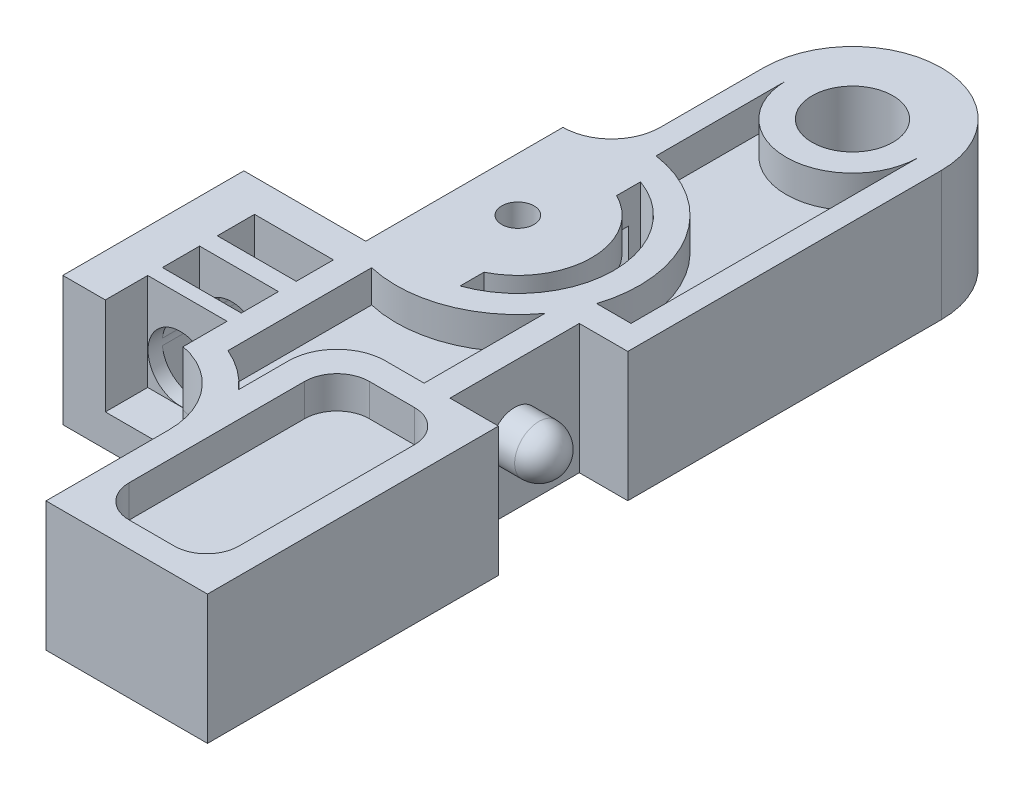
from build123d import *

# Parameters (mm, degrees)
SKETCH1_W           = 21.55
SKETCH1_H           = 50.9
BOSS_EXTRUDE1_DEPTH = 8
SKETCH2_W           = 3
SKETCH2_H           = 8
SKETCH2_W_2         = 11.56
SKETCH2_H_2         = 12.6
CUT_EXTRUDE1_DEPTH  = 10
SKETCH4_R           = 1
CUT_EXTRUDE2_DEPTH  = 10
CUT_EXTRUDE3_START  = -2
SKETCH5_R           = 5.25
CUT_EXTRUDE3_DEPTH  = 4
CUT_EXTRUDE4_DEPTH  = 8
SKETCH7_R           = 2.5
CUT_EXTRUDE5_DEPTH  = 8
SKETCH8_R           = 1.5
BOSS_EXTRUDE2_DEPTH = 3
FILLET1_R           = 1.5
CUT_EXTRUDE6_REACH  = 40.3
SKETCH9_R           = 2
FILLET2_R           = 5
SKETCH10_W          = 4.879401489
SKETCH10_H          = 2.3
CUT_EXTRUDE7_DEPTH  = 8
SKETCH11_W          = 4.90836959
SKETCH11_H          = 2.717270837
CUT_EXTRUDE8_DEPTH  = 6
CUT_EXTRUDE9_DEPTH  = 2
CUT_EXTRUDE11_DEPTH = 2
CUT_EXTRUDE12_DEPTH = 2
FILLET3_R           = 3
FILLET4_R           = 2
CUT_EXTRUDE13_DEPTH = 2
SKETCH16_W          = 2
SKETCH16_H          = 3
CUT_EXTRUDE14_DEPTH = 7
BOSS_EXTRUDE3_DEPTH = 2


with BuildPart() as part:
    # Sketch1 → Boss-Extrude1 (new body)
    with BuildSketch(Plane(origin=(0, 0, 0), x_dir=(1, 0, 0), z_dir=(0, 1, 0))):
        with Locations((-10.785, 25.45)):
            Rectangle(SKETCH1_W, SKETCH1_H)
    extrude(amount=BOSS_EXTRUDE1_DEPTH)

    # Sketch2 → Cut-Extrude1 (cut)
    with BuildSketch(Plane(origin=(0, 8, 0), x_dir=(1, 0, 0), z_dir=(0, 1, 0))):
        with BuildLine():
            ThreePointArc((-14.020598511, 36), (-11.891783888, 36.881783888), (-11.01, 39.010598511))
            Line((-11.01, 39.010598511), (-11.01, 45.4))
            ThreePointArc((-11.01, 45.4), (-9.399087308, 49.289087285), (-5.510000032, 50.9))
            Line((-5.510000032, 50.9), (-21.56, 50.9))
            Line((-21.56, 50.9), (-21.56, 23.8))
            Line((-21.56, 23.8), (-14.020598511, 23.8))
            Line((-14.020598511, 23.8), (-14.020598511, 36))
        make_face()
        with BuildLine():
            Line((-0.01, 50.9), (-5.510000032, 50.9))
            ThreePointArc((-5.510000032, 50.9), (-1.620912715, 49.289087308), (-0.01, 45.4))
            Line((-0.01, 45.4), (-0.01, 50.9))
        make_face()
        with Locations((-1.51, 22)):
            Rectangle(SKETCH2_W, SKETCH2_H)
        with Locations((-15.78, 6.3)):
            Rectangle(SKETCH2_W_2, SKETCH2_H_2)
    extrude(amount=-CUT_EXTRUDE1_DEPTH, mode=Mode.SUBTRACT)

    # Sketch4 → Cut-Extrude2 (cut)
    with BuildSketch(Plane(origin=(0, 8, 0), x_dir=(1, 0, 0), z_dir=(0, 1, 0))):
        with Locations((-10.71, 29.9)):
            Circle(SKETCH4_R)
    extrude(amount=-CUT_EXTRUDE2_DEPTH, mode=Mode.SUBTRACT)

    # Sketch5 → Cut-Extrude3 (cut)
    with BuildSketch(Plane(origin=(0, 8, 0), x_dir=(1, 0, 0), z_dir=(0, 1, 0)).offset(CUT_EXTRUDE3_START)):
        with Locations((-10.71, 29.9)):
            Circle(SKETCH5_R)
    extrude(amount=-CUT_EXTRUDE3_DEPTH, mode=Mode.SUBTRACT)

    # Sketch6 → Cut-Extrude4 (cut)
    with BuildSketch(Plane(origin=(0, 8, 0), x_dir=(1, 0, 0), z_dir=(0, 1, 0))):
        with BuildLine():
            Line((-8.703613469, 35.482647313), (-8.703613469, 33.999886934))
            ThreePointArc((-8.703613469, 33.999886934), (-6.145500051, 29.9), (-8.703613469, 25.800113066))
            Line((-8.703613469, 25.800113066), (-8.703613469, 24.317352687))
            ThreePointArc((-8.703613469, 24.317352687), (-4.777754394, 29.9), (-8.703613469, 35.482647313))
        make_face()
    extrude(amount=-CUT_EXTRUDE4_DEPTH, mode=Mode.SUBTRACT)

    # Sketch7 → Cut-Extrude5 (cut)
    with BuildSketch(Plane(origin=(0, 8, 0), x_dir=(1, 0, 0), z_dir=(0, 1, 0))):
        with Locations((-5.51, 45.4)):
            Circle(SKETCH7_R)
    extrude(amount=-CUT_EXTRUDE5_DEPTH, mode=Mode.SUBTRACT)

    # Sketch8 → Boss-Extrude2 (add)
    with BuildSketch(Plane(origin=(-3.01, 0, 0), x_dir=(0, 0, -1), z_dir=(1, 0, 0))):
        with Locations((22, 4)):
            Circle(SKETCH8_R)
    extrude(amount=BOSS_EXTRUDE2_DEPTH)

    # Fillet1
    fillet1_edges = [part.edges().sort_by_distance(p)[0] for p in [
        (-0.01, 4, -20.5),
    ]]
    fillet(fillet1_edges, radius=FILLET1_R)

    # Sketch9 → Cut-Extrude6 (cut, up to next)
    with BuildSketch(Plane.XY.offset(-12.6), mode=Mode.PRIVATE) as cut_extrude6_sk1:
        with Locations((-16.91, 4.013647605)):
            Circle(SKETCH9_R)
    cut_extrude6_tool1 = extrude(cut_extrude6_sk1.sketch, amount=-CUT_EXTRUDE6_REACH, mode=Mode.PRIVATE) & part.part
    add(cut_extrude6_tool1.solids().sort_by_distance((-16.91, 4.013648, -12.6))[0], mode=Mode.SUBTRACT)

    # Fillet2
    fillet2_edges = [part.edges().sort_by_distance(p)[0] for p in [
        (-10, 4, -12.6),
    ]]
    fillet(fillet2_edges, radius=FILLET2_R)

    # Sketch10 → Cut-Extrude7 (cut)
    with BuildSketch(Plane(origin=(0, 8, 0), x_dir=(1, 0, 0), z_dir=(0, 1, 0))):
        with Locations((-16.460299256, 20.65)):
            Rectangle(SKETCH10_W, SKETCH10_H)
        with Locations((-16.460299256, 17.25)):
            Rectangle(SKETCH10_W, SKETCH10_H)
    extrude(amount=-CUT_EXTRUDE7_DEPTH, mode=Mode.SUBTRACT)

    # Sketch11 → Cut-Extrude8 (cut)
    with BuildSketch(Plane(origin=(0, 8, 0), x_dir=(1, 0, 0), z_dir=(0, 1, 0))):
        with Locations((-16.474783306, 13.861774486)):
            Rectangle(SKETCH11_W, SKETCH11_H)
    extrude(amount=-CUT_EXTRUDE8_DEPTH, mode=Mode.SUBTRACT)

    # Sketch12 → Cut-Extrude9 (cut)
    with BuildSketch(Plane(origin=(0, 8, 0), x_dir=(1, 0, 0), z_dir=(0, 1, 0))):
        with BuildLine():
            Line((-9.61, 45.4), (-9.61, 37.351491386))
            ThreePointArc((-9.61, 37.351491386), (-4.316139602, 33.881616893), (-3.537502257, 27.6))
            Line((-3.537502257, 27.6), (-1.41, 27.6))
            Line((-1.41, 27.6), (-1.41, 45.4))
            ThreePointArc((-1.41, 45.4), (-5.51, 41.3), (-9.61, 45.4))
        make_face()
    extrude(amount=-CUT_EXTRUDE9_DEPTH, mode=Mode.SUBTRACT)

    # Sketch13 → Cut-Extrude11 (cut)
    with BuildSketch(Plane.XZ):
        with BuildLine():
            Line((-1.41, -27.6), (-3.537502257, -27.6))
            ThreePointArc((-3.537502257, -27.6), (-4.316139602, -33.881616893), (-9.61, -37.351491386))
            Line((-9.61, -37.351491386), (-9.61, -45.4))
            ThreePointArc((-9.61, -45.4), (-5.51, -41.3), (-1.41, -45.4))
            Line((-1.41, -45.4), (-1.41, -27.6))
        make_face()
    extrude(amount=-CUT_EXTRUDE11_DEPTH, mode=Mode.SUBTRACT)

    # Sketch14 → Cut-Extrude12 (cut)
    with BuildSketch(Plane(origin=(0, 8, 0), x_dir=(1, 0, 0), z_dir=(0, 1, 0))):
        with BuildLine():
            Line((-12.420598511, 22.564567047), (-12.420598511, 13.675087486))
            ThreePointArc((-12.420598511, 13.675087486), (-11.108680842, 12.930819375), (-10, 11.908131846))
            Line((-10, 11.908131846), (-10, 18))
            Line((-10, 18), (-4.61, 18))
            Line((-4.61, 18), (-4.61, 25.481321027))
            ThreePointArc((-4.61, 25.481321027), (-8.074933625, 22.843715633), (-12.420598511, 22.564567047))
        make_face()
        with BuildLine():
            Line((-6.4, 16.4), (-3.61, 16.4))
            ThreePointArc((-3.61, 16.4), (-2.195786438, 15.814213562), (-1.61, 14.4))
            Line((-1.61, 14.4), (-1.61, 1.546839651))
            Line((-1.61, 1.546839651), (-8.4, 1.546839651))
            Line((-8.4, 1.546839651), (-8.4, 14.4))
            ThreePointArc((-8.4, 14.4), (-7.814213562, 15.814213562), (-6.4, 16.4))
        make_face()
    extrude(amount=-CUT_EXTRUDE12_DEPTH, mode=Mode.SUBTRACT)

    # Fillet3
    fillet3_edges = [part.edges().sort_by_distance(p)[0] for p in [
        (-10, 7, -18),
    ]]
    fillet(fillet3_edges, radius=FILLET3_R)

    # Fillet4
    fillet4_edges = [part.edges().sort_by_distance(p)[0] for p in [
        (-1.61, 7, -1.546839651),
        (-8.4, 7, -1.546839651),
    ]]
    fillet(fillet4_edges, radius=FILLET4_R)

    # Sketch15 → Cut-Extrude13 (cut)
    with BuildSketch(Plane(origin=(0, 0, 0), x_dir=(-1, 0, 0), z_dir=(0, -1, 0))):
        with BuildLine():
            Line((6.4, 1.546839651), (3.61, 1.546839651))
            ThreePointArc((3.61, 1.546839651), (2.195786438, 2.132626089), (1.61, 3.546839651))
            Line((1.61, 3.546839651), (1.61, 14.4))
            ThreePointArc((1.61, 14.4), (2.195786438, 15.814213562), (3.61, 16.4))
            Line((3.61, 16.4), (6.4, 16.4))
            ThreePointArc((6.4, 16.4), (7.814213562, 15.814213562), (8.4, 14.4))
            Line((8.4, 14.4), (8.4, 3.546839651))
            ThreePointArc((8.4, 3.546839651), (7.814213562, 2.132626089), (6.4, 1.546839651))
        make_face()
        with BuildLine():
            Line((4.61, 18), (4.61, 25.481321027))
            ThreePointArc((4.61, 25.481321027), (8.074933625, 22.843715633), (12.420598511, 22.564567047))
            Line((12.420598511, 22.564567047), (12.420598511, 13.675087486))
            ThreePointArc((12.420598511, 13.675087486), (11.108680842, 12.930819375), (10, 11.908131846))
            Line((10, 11.908131846), (10, 15))
            ThreePointArc((10, 15), (9.121320344, 17.121320344), (7, 18))
            Line((7, 18), (4.61, 18))
        make_face()
    extrude(amount=-CUT_EXTRUDE13_DEPTH, mode=Mode.SUBTRACT)

    # Sketch16 → Cut-Extrude14 (cut)
    with BuildSketch(Plane.ZY.offset(21.56)):
        with Locations((-22.8, 4)):
            Rectangle(SKETCH16_W, SKETCH16_H)
    extrude(amount=-CUT_EXTRUDE14_DEPTH, mode=Mode.SUBTRACT)

    # Sketch17 → Boss-Extrude3 (add)
    with BuildSketch(Plane(origin=(0, 0, -23.8), x_dir=(-1, 0, 0), z_dir=(0, 0, -1))):
        with BuildLine():
            Line((15.602762099, 2.5), (18.217237901, 2.5))
            ThreePointArc((18.217237901, 2.5), (16.91, 2.013647605), (15.602762099, 2.5))
        make_face()
        with BuildLine():
            Line((15.571808475, 5.5), (18.248191525, 5.5))
            ThreePointArc((18.248191525, 5.5), (16.91, 6.013647605), (15.571808475, 5.5))
        make_face()
    extrude(amount=-BOSS_EXTRUDE3_DEPTH)


solid = part.part
